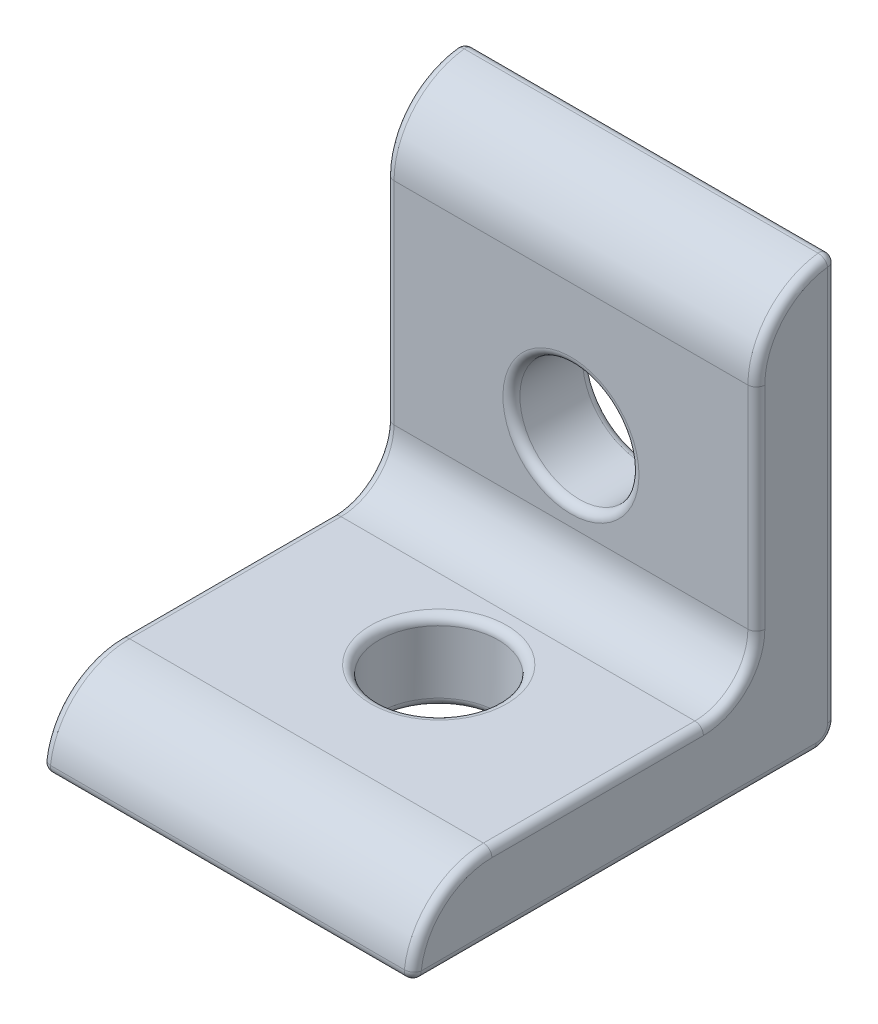
from build123d import *

# Parameters (mm, degrees)
BOSS_EXTRUDE1_START = 11.1125
BOSS_EXTRUDE1_DEPTH = 22.225
FILLET1_R           = 1.1938
SKETCH4_R           = 3.5687
CUT_EXTRUDE1_DEPTH  = 5.7752
SKETCH5_R           = 3.5687
CUT_EXTRUDE2_DEPTH  = 5.7752
FILLET2_R           = 0.508
FILLET3_R           = 0.508


with BuildPart() as part:
    # Sketch3 → Boss-Extrude1 (new body)
    with BuildSketch(Plane(origin=(0, 0, 0), x_dir=(0, 0, -1), z_dir=(1, 0, 0)).offset(BOSS_EXTRUDE1_START)):
        with BuildLine():
            Line((-3.175, -7.9248), (-15.8496, -7.9248))
            ThreePointArc((-15.8496, -7.9248), (-19.226176302, -9.323423698), (-20.6248, -12.7))
            Line((-20.6248, -12.7), (4.7752, -12.7))
            Line((4.7752, -12.7), (4.7752, 12.7))
            ThreePointArc((4.7752, 12.7), (1.398623698, 11.301376302), (0, 7.9248))
            Line((0, 7.9248), (0, -4.7498))
            ThreePointArc((0, -4.7498), (-0.92993597, -6.99486403), (-3.175, -7.9248))
        make_face()
    extrude(amount=-BOSS_EXTRUDE1_DEPTH)

    # Fillet1
    fillet1_edges = [part.edges().sort_by_distance(p)[0] for p in [
        (0, -12.7, -4.7752),
    ]]
    fillet(fillet1_edges, radius=FILLET1_R)

    # Sketch4 → Cut-Extrude1 (cut, through all)
    with BuildSketch(Plane.XY):
        Circle(SKETCH4_R)
    extrude(amount=-CUT_EXTRUDE1_DEPTH, mode=Mode.SUBTRACT)

    # Sketch5 → Cut-Extrude2 (cut, through all)
    with BuildSketch(Plane(origin=(0, -7.9248, 0), x_dir=(1, 0, 0), z_dir=(0, 1, 0))):
        with Locations((0, -7.9248)):
            Circle(SKETCH5_R)
    extrude(amount=-CUT_EXTRUDE2_DEPTH, mode=Mode.SUBTRACT)

    # Fillet2
    fillet2_edges = [part.edges().sort_by_distance(p)[0] for p in [
        (0, 12.7, -4.7752),
        (0, -12.7, 20.6248),
        (-11.1125, 11.301376302, -1.398623698),
        (-11.1125, 1.5875, 0),
        (-11.1125, -6.99486403, 0.92993597),
        (11.1125, 0.5969, -4.7752),
        (-11.1125, -7.9248, 9.5123),
        (11.1125, -12.350344075, -4.425544075),
        (-11.1125, 0.5969, -4.7752),
        (-11.1125, -12.350344075, -4.425544075),
        (-3.5687, -12.7, 7.9248),
        (-11.1125, -9.323423698, 19.226176302),
        (11.1125, -7.9248, 9.5123),
        (-11.1125, -12.7, 8.5217),
        (11.1125, -6.99486403, 0.92993597),
        (11.1125, 1.5875, 0),
        (11.1125, 11.301376302, -1.398623698),
        (11.1125, -12.7, 8.5217),
        (11.1125, -9.323423698, 19.226176302),
    ]]
    fillet(fillet2_edges, radius=FILLET2_R)

    # Fillet3
    fillet3_edges = [part.edges().sort_by_distance(p)[0] for p in [
        (-3.5687, 0, -4.7752),
        (-3.5687, 0, 0),
        (-3.5687, -7.9248, 7.9248),
    ]]
    fillet(fillet3_edges, radius=FILLET3_R)


solid = part.part
